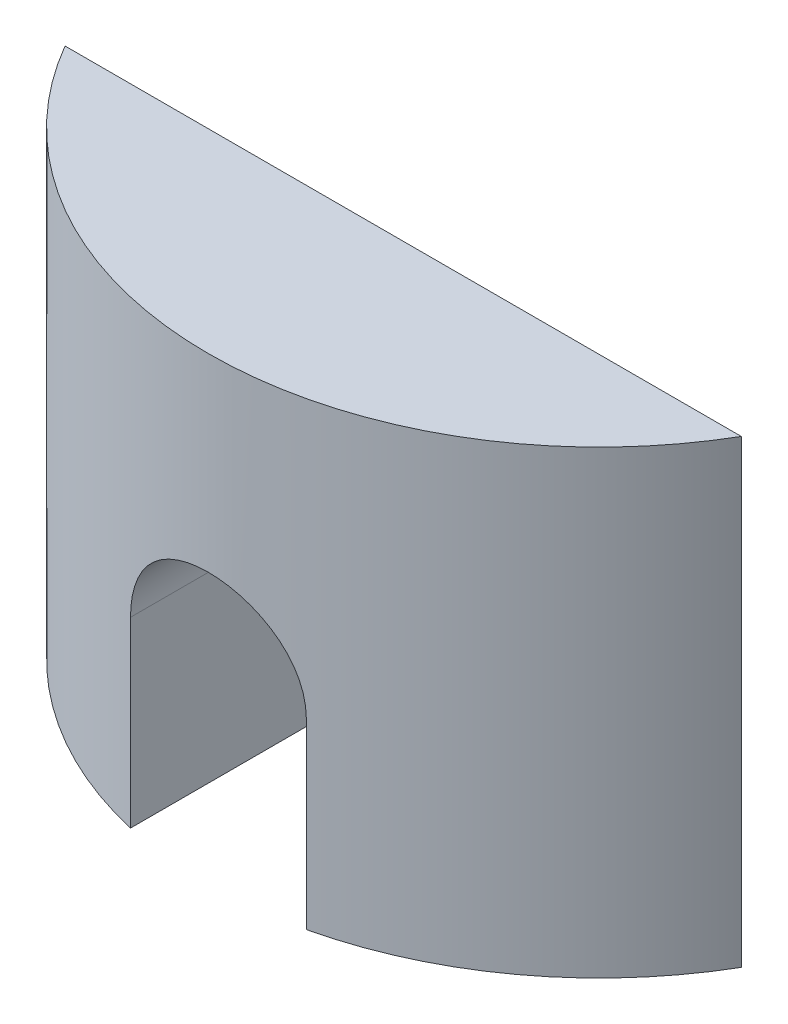
from build123d import *

# Parameters (mm, degrees)
BOSS_EXTRUDE1_DEPTH = 17
CUT_EXTRUDE1_REACH  = 9.2


with BuildPart() as part:
    # Sketch2 → Boss-Extrude1 (new body)
    with BuildSketch(Plane(origin=(0, 0, 0), x_dir=(1, 0, 0), z_dir=(0, 1, 0))):
        with BuildLine():
            Line((0, 0), (25, 0))
            ThreePointArc((25, 0), (12.5, -7.2), (0, 0))
        make_face()
    extrude(amount=BOSS_EXTRUDE1_DEPTH)

    # Sketch3 → Cut-Extrude1 (cut, up to next)
    with BuildSketch(Plane(origin=(0, 0, 0), x_dir=(-1, 0, 0), z_dir=(0, 0, -1)), mode=Mode.PRIVATE) as cut_extrude1_sk1:
        with BuildLine():
            Line((-15.75, 0), (-15.75, 6.75))
            ThreePointArc((-15.75, 6.75), (-12.5, 10), (-9.25, 6.75))
            Line((-9.25, 6.75), (-9.25, 0))
            Line((-9.25, 0), (-15.75, 0))
        make_face()
    cut_extrude1_tool1 = extrude(cut_extrude1_sk1.sketch, amount=-CUT_EXTRUDE1_REACH, mode=Mode.PRIVATE) & part.part
    add(cut_extrude1_tool1.solids().sort_by_distance((12.5, 4.679554, 0))[0], mode=Mode.SUBTRACT)


solid = part.part
